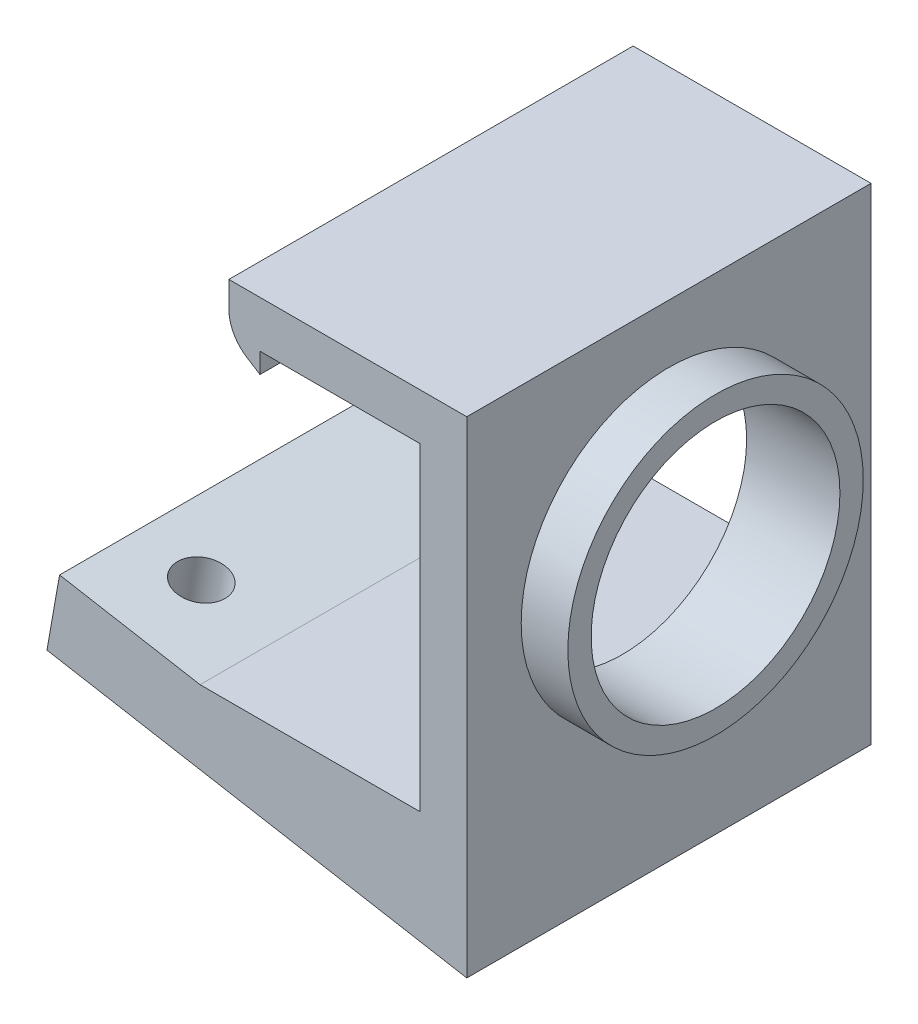
from build123d import *

# Parameters (mm, degrees)
BOSS_EXTRUDE1_DEPTH = 26
SKETCH2_R           = 8
CUT_EXTRUDE1_DEPTH  = 26
SKETCH3_R           = 9.5
SKETCH3_R_2         = 8
BOSS_EXTRUDE2_DEPTH = 3
BOSS_EXTRUDE4_DEPTH = 26
SKETCH5_R           = 1.55
CUT_EXTRUDE2_DEPTH  = 10.353024773
CUT_EXTRUDE3_DEPTH  = 27


with BuildPart() as part:
    # Sketch1 → Boss-Extrude1 (new body)
    with BuildSketch(Plane.XY):
        with BuildLine():
            Line((0, 0), (27, 0))
            Line((27, 0), (27, 26.5))
            Line((27, 26.5), (13.7, 26.5))
            Line((13.7, 26.5), (11.7, 26.5))
            Line((11.7, 26.5), (11.7, 24.839060942))
            ThreePointArc((11.7, 24.839060942), (12.011588642, 23.630402293), (12.868684584, 22.72302709))
            Line((12.868684584, 22.72302709), (13.7, 22.2))
            Line((13.7, 22.2), (13.7, 23.5))
            Line((13.7, 23.5), (24, 23.5))
            Line((24, 23.5), (24, 3))
            Line((24, 3), (0, 3))
            Line((0, 3), (0, 0))
        make_face()
    extrude(amount=BOSS_EXTRUDE1_DEPTH)

    # Sketch2 → Cut-Extrude1 (cut)
    with BuildSketch(Plane(origin=(27, 0, 0), x_dir=(0, 0, -1), z_dir=(1, 0, 0))):
        with Locations((-13, 13.25)):
            Circle(SKETCH2_R)
    extrude(amount=-CUT_EXTRUDE1_DEPTH, mode=Mode.SUBTRACT)

    # Sketch3 → Boss-Extrude2 (add)
    with BuildSketch(Plane(origin=(27, 0, 0), x_dir=(0, 0, -1), z_dir=(1, 0, 0))):
        with Locations((-13, 13.25)):
            Circle(SKETCH3_R)
        with Locations((-13, 13.25)):
            Circle(SKETCH3_R_2, mode=Mode.SUBTRACT)
    extrude(amount=BOSS_EXTRUDE2_DEPTH)

    # Sketch4 → Boss-Extrude4 (add)
    with BuildSketch(Plane(origin=(0, 0, 0), x_dir=(-1, 0, 0), z_dir=(0, 0, -1))):
        Polygon((-9.84807753, 3), (0, 3), (0, 4.736481777), align=None)
        Polygon((-27, 0), (0, 0), (-27, -4.760828479), align=None)
    extrude(amount=-BOSS_EXTRUDE4_DEPTH)

    # Sketch5 → Cut-Extrude2 (cut, through all)
    with BuildSketch(Plane(origin=(0.809986088, 4.593659375, 0), x_dir=(0.984807753, -0.173648178, 0), z_dir=(0.173648178, 0.984807753, 0))):
        with Locations((4.177518571, -5)):
            Circle(SKETCH5_R)
        with Locations((4.177518571, -21)):
            Circle(SKETCH5_R)
    extrude(amount=-CUT_EXTRUDE2_DEPTH, mode=Mode.SUBTRACT)

    # Sketch6 → Cut-Extrude3 (cut, through all)
    with BuildSketch(Plane(origin=(0, 0, 0), x_dir=(-1, 0, 0), z_dir=(0, 0, -1))):
        Polygon((0, 0), (-0.809986088, 4.593659375), (0, 4.736481777), align=None)
    extrude(amount=-CUT_EXTRUDE3_DEPTH, mode=Mode.SUBTRACT)


solid = part.part
